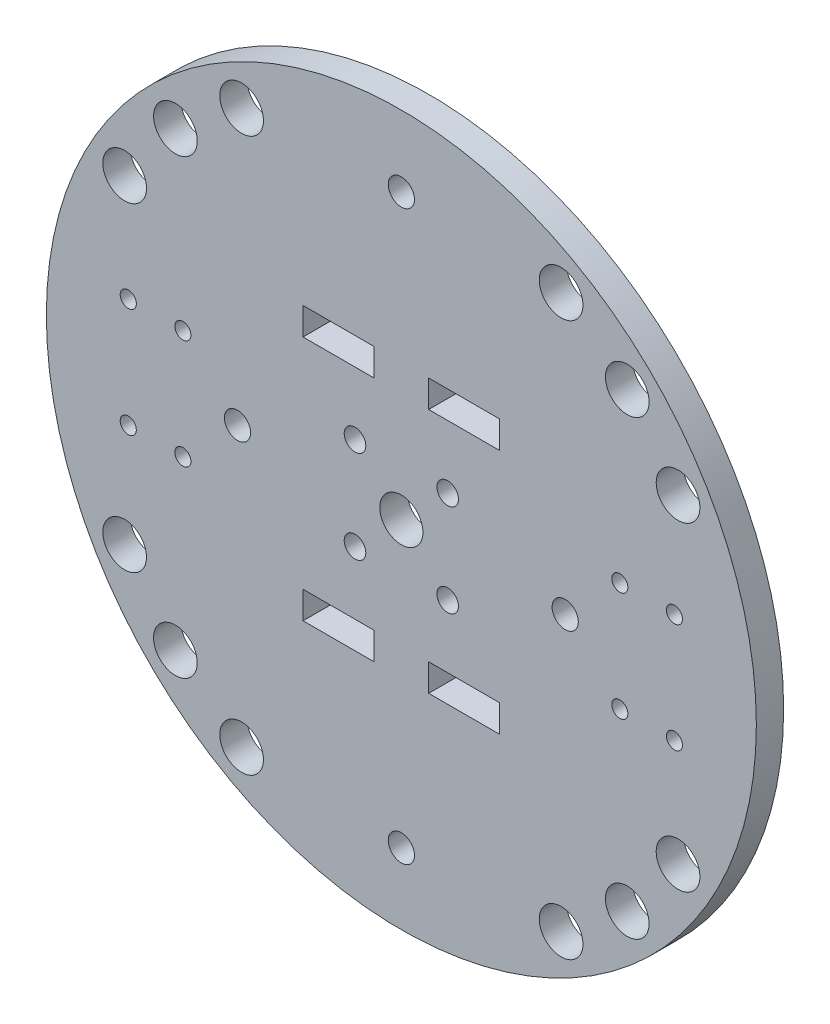
from build123d import *

# Parameters (mm, degrees)
SKETCH1_R           = 65
SKETCH1_R_2         = 3.95
SKETCH1_R_3         = 2.4
SKETCH1_R_4         = 4
SKETCH1_R_5         = 1.475
SKETCH1_R_6         = 1.975
SKETCH1_W           = 13
SKETCH1_H           = 5
BOSS_EXTRUDE1_DEPTH = 5


with BuildPart() as part:
    # Sketch1 → Boss-Extrude1 (new body)
    with BuildSketch(Plane.XY):
        Circle(SKETCH1_R)
        Circle(SKETCH1_R_2, mode=Mode.SUBTRACT)
        with Locations((0, 52)):
            Circle(SKETCH1_R_3, mode=Mode.SUBTRACT)
        with Locations((-30, 0)):
            Circle(SKETCH1_R_3, mode=Mode.SUBTRACT)
        with Locations((0, -52)):
            Circle(SKETCH1_R_3, mode=Mode.SUBTRACT)
        with Locations((30, 0)):
            Circle(SKETCH1_R_3, mode=Mode.SUBTRACT)
        with Locations((-41.365746699, 41.365746699)):
            Circle(SKETCH1_R_4, mode=Mode.SUBTRACT)
        with Locations((-29.25, 50.662486121)):
            Circle(SKETCH1_R_4, mode=Mode.SUBTRACT)
        with Locations((-50.662486121, 29.25)):
            Circle(SKETCH1_R_4, mode=Mode.SUBTRACT)
        with Locations((50.662486121, 29.25)):
            Circle(SKETCH1_R_4, mode=Mode.SUBTRACT)
        with Locations((41.365746699, 41.365746699)):
            Circle(SKETCH1_R_4, mode=Mode.SUBTRACT)
        with Locations((29.25, 50.662486121)):
            Circle(SKETCH1_R_4, mode=Mode.SUBTRACT)
        with Locations((50.662486121, -29.25)):
            Circle(SKETCH1_R_4, mode=Mode.SUBTRACT)
        with Locations((41.365746699, -41.365746699)):
            Circle(SKETCH1_R_4, mode=Mode.SUBTRACT)
        with Locations((29.25, -50.662486121)):
            Circle(SKETCH1_R_4, mode=Mode.SUBTRACT)
        with Locations((-29.25, -50.662486121)):
            Circle(SKETCH1_R_4, mode=Mode.SUBTRACT)
        with Locations((-41.365746699, -41.365746699)):
            Circle(SKETCH1_R_4, mode=Mode.SUBTRACT)
        with Locations((-50.662486121, -29.25)):
            Circle(SKETCH1_R_4, mode=Mode.SUBTRACT)
        with Locations((-40, 10)):
            Circle(SKETCH1_R_5, mode=Mode.SUBTRACT)
        with Locations((-50, 10)):
            Circle(SKETCH1_R_5, mode=Mode.SUBTRACT)
        with Locations((-40, -10)):
            Circle(SKETCH1_R_5, mode=Mode.SUBTRACT)
        with Locations((-50, -10)):
            Circle(SKETCH1_R_5, mode=Mode.SUBTRACT)
        with Locations((50, -10)):
            Circle(SKETCH1_R_5, mode=Mode.SUBTRACT)
        with Locations((40, -10)):
            Circle(SKETCH1_R_5, mode=Mode.SUBTRACT)
        with Locations((40, 10)):
            Circle(SKETCH1_R_5, mode=Mode.SUBTRACT)
        with Locations((50, 10)):
            Circle(SKETCH1_R_5, mode=Mode.SUBTRACT)
        with Locations((-8.485281374, 8.485281374)):
            Circle(SKETCH1_R_6, mode=Mode.SUBTRACT)
        with Locations((8.485281374, 8.485281374)):
            Circle(SKETCH1_R_6, mode=Mode.SUBTRACT)
        with Locations((8.485281374, -8.485281374)):
            Circle(SKETCH1_R_6, mode=Mode.SUBTRACT)
        with Locations((-8.485281374, -8.485281374)):
            Circle(SKETCH1_R_6, mode=Mode.SUBTRACT)
        with Locations((11.5, 22.5)):
            Rectangle(SKETCH1_W, SKETCH1_H, mode=Mode.SUBTRACT)
        with Locations((-11.5, 22.5)):
            Rectangle(SKETCH1_W, SKETCH1_H, mode=Mode.SUBTRACT)
        with Locations((11.5, -22.5)):
            Rectangle(SKETCH1_W, SKETCH1_H, mode=Mode.SUBTRACT)
        with Locations((-11.5, -22.5)):
            Rectangle(SKETCH1_W, SKETCH1_H, mode=Mode.SUBTRACT)
    extrude(amount=BOSS_EXTRUDE1_DEPTH)


solid = part.part
